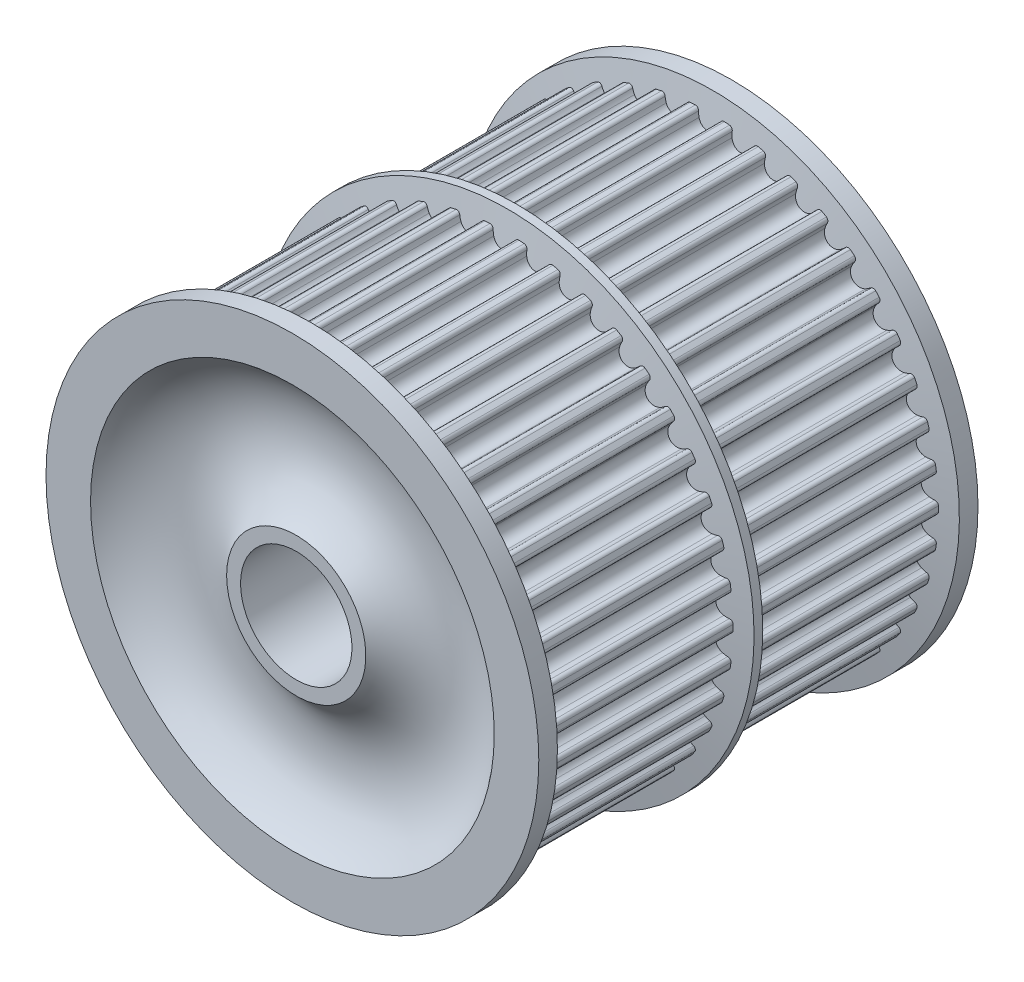
from build123d import *

# Parameters (mm, degrees)
SKETCH1_R           = 35.5
SKETCH1_R_2         = 8
BOSS_EXTRUDE1_DEPTH = 31.55
CUT_EXTRUDE1_START  = -60.295046167
CUT_EXTRUDE1_DEPTH  = 119.090092335
CIRPATTERN1_COUNT   = 42


with BuildPart() as part:
    # Sketch1 → Boss-Extrude1 (new, symmetric)
    with BuildSketch(Plane.XY):
        Circle(SKETCH1_R)
        Circle(SKETCH1_R_2, mode=Mode.SUBTRACT)
    extrude(amount=BOSS_EXTRUDE1_DEPTH, both=True)

    # Sketch3 → Cut-Revolve1 (revolve, cut)
    with BuildSketch(Plane(origin=(0, 0, 0), x_dir=(0, 0, -1), z_dir=(1, 0, 0))):
        with BuildLine():
            Line((-31, 0), (-31.55, 0))
            Line((-31.55, 0), (-31.55, 10))
            Line((-31.55, 10), (-31.55, 29))
            ThreePointArc((-31.55, 29), (-26.554993293, 19.636631773), (-31, 10))
            Line((-31, 10), (-31, 0))
        make_face()
        with BuildLine():
            Line((31.55, 0), (31, 0))
            Line((31, 0), (31, 10))
            ThreePointArc((31, 10), (26.554993293, 19.636631773), (31.55, 29))
            Line((31.55, 29), (31.55, 10))
            Line((31.55, 10), (31.55, 0))
        make_face()
    revolve(axis=Axis((0, 0, 0), (0, 0, 1)), mode=Mode.SUBTRACT)

    # Sketch6 → Cut-Extrude1 (cut)
    with BuildSketch(Plane.XY.offset(CUT_EXTRUDE1_START)):
        with BuildLine():
            Line((-4, 32.603997721), (-4.512890758, 36.78457))
            Line((-4.512890758, 36.78457), (4.512890758, 36.78457))
            Line((4.512890758, 36.78457), (4, 32.603997721))
            ThreePointArc((4, 32.603997721), (3.04343887, 32.707157431), (2.084266889, 32.782258905))
            ThreePointArc((2.084266889, 32.782258905), (1.729605106, 32.670356497), (1.542590939, 32.348902253))
            ThreePointArc((1.542590939, 32.348902253), (1.468177302, 32.017226623), (1.352726008, 31.697512514))
            ThreePointArc((1.352726008, 31.697512514), (0, 30.80995), (-1.352726008, 31.697512514))
            ThreePointArc((-1.352726008, 31.697512514), (-1.468177302, 32.017226623), (-1.542590939, 32.348902253))
            ThreePointArc((-1.542590939, 32.348902253), (-1.729605106, 32.670356497), (-2.084266889, 32.782258905))
            ThreePointArc((-2.084266889, 32.782258905), (-3.04343887, 32.707157431), (-4, 32.603997721))
        make_face()
    cut_extrude1 = extrude(amount=CUT_EXTRUDE1_DEPTH, mode=Mode.SUBTRACT)

    # CirPattern1: Cut-Extrude1 ×42 about axis
    cirpattern1_axis = Axis((0, 0, -80.9), (0, 0, 1))
    for i in range(1, CIRPATTERN1_COUNT):
        add(cut_extrude1.rotate(cirpattern1_axis, i * 360 / CIRPATTERN1_COUNT), mode=Mode.SUBTRACT)

    # Sketch7 → Revolve1 (revolve)
    with BuildSketch(Plane(origin=(0, 0, 0), x_dir=(0, 0, -1), z_dir=(1, 0, 0))):
        Polygon((1.5, 30.440124204), (-1.5, 30.440124204), (-0.625440076, 35.4), (0.625440076, 35.4), align=None)
        Polygon((31.55, 35.4), (28.874559924, 35.4), (28, 30.440124204), (31.55, 30.440124204), align=None)
        Polygon((-31.55, 30.440124204), (-28, 30.440124204), (-28.874559924, 35.4), (-31.55, 35.4), align=None)
    revolve(axis=Axis((0, 0, 7.216998163), (0, 0, -1)))


solid = part.part
